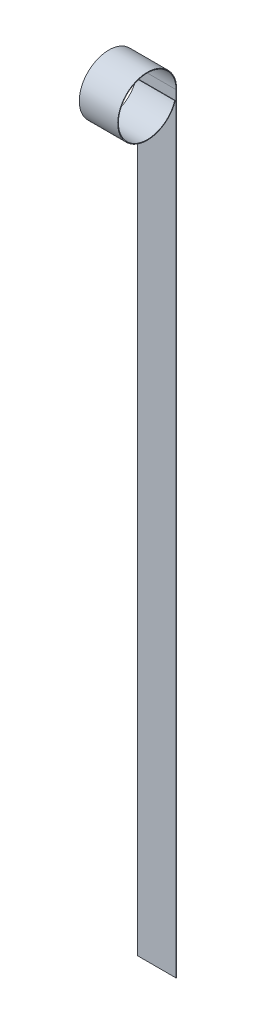
from build123d import *

# Parameters (mm, degrees)
EXTRUDE_THIN2_DEPTH = 19.05


with BuildPart() as part:
    # Sketch1 → Extrude-Thin2 (new body, symmetric)
    with BuildSketch(Plane(origin=(0, 0, 0), x_dir=(0, 0, -1), z_dir=(1, 0, 0))):
        with BuildLine():
            ThreePointArc((27.214858383, -8.711033705), (-28.232916988, 4.408290299), (28.575, 0))
            Line((28.575, 0), (28.575, -762))
            Line((28.575, -762), (29.21, -762))
            Line((29.21, -762), (29.21, 0))
            ThreePointArc((29.21, 0), (-28.860315143, 4.506252306), (27.819633013, -8.904612232))
            Line((27.819633013, -8.904612232), (27.214858383, -8.711033705))
        make_face()
    extrude(amount=EXTRUDE_THIN2_DEPTH, both=True)


solid = part.part
